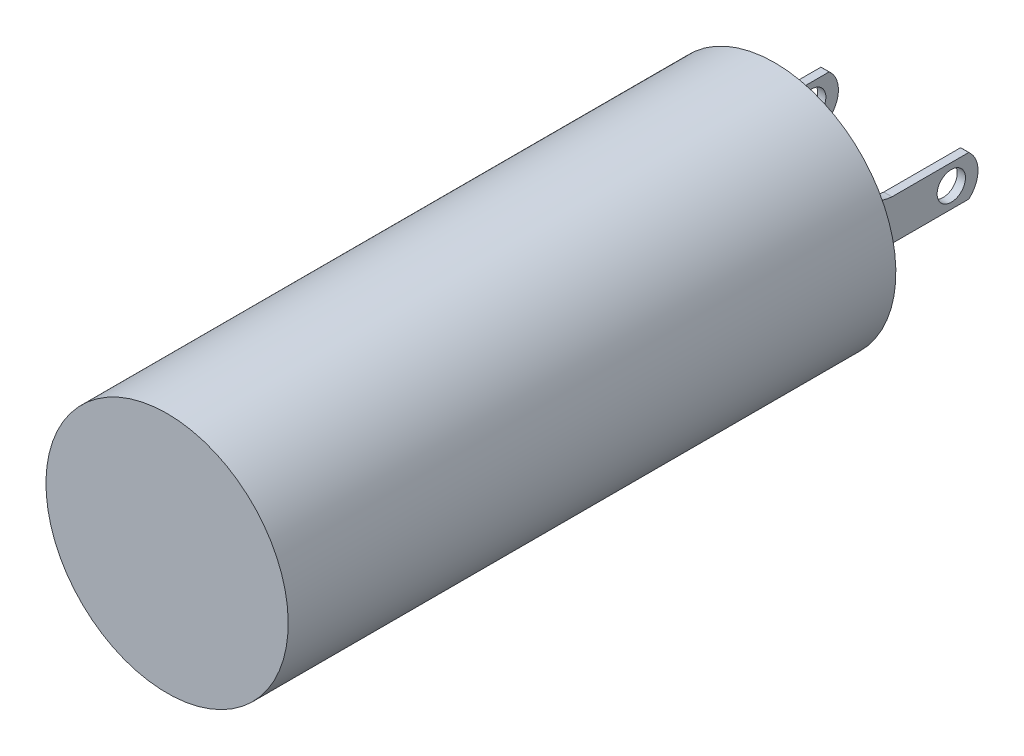
from build123d import *

# Parameters (mm, degrees)
SKETCH3_R           = 0.35052
BOSS_EXTRUDE1_DEPTH = 0.2032


with BuildPart() as part:
    # Sketch1 → Revolve1 (revolve)
    with BuildSketch(Plane(origin=(0, 0, 0), x_dir=(0, 0, -1), z_dir=(1, 0, 0))):
        Polygon((0, 0), (0, 2.9972), (15.0368, 2.9972), (15.0368, 1.5875), (15.4178, 1.5875), (15.4178, 0), align=None)
    revolve(axis=Axis((0, 0, -15.4178), (0, 0, 1)))

    # Sketch3 → Boss-Extrude1 (add)
    with BuildSketch(Plane(origin=(1.6256, 0, 0), x_dir=(0, 0, -1), z_dir=(1, 0, 0))):
        with BuildLine():
            Line((15.0368, 0.635), (15.0368, -0.635))
            Line((15.0368, -0.635), (15.6718, -0.635))
            ThreePointArc((15.6718, -0.635), (15.882828569, -0.543684888), (16.108651936, -0.50038))
            Line((16.108651936, -0.50038), (18.0086, -0.50038))
            ThreePointArc((18.0086, -0.50038), (18.237732209, 0), (18.0086, 0.50038))
            Line((18.0086, 0.50038), (16.108651936, 0.50038))
            ThreePointArc((16.108651936, 0.50038), (15.882828569, 0.543684888), (15.6718, 0.635))
            Line((15.6718, 0.635), (15.0368, 0.635))
        make_face()
        with Locations((17.5768, 0)):
            Circle(SKETCH3_R, mode=Mode.SUBTRACT)
    boss_extrude1 = extrude(amount=BOSS_EXTRUDE1_DEPTH)

    # Mirror1: Boss-Extrude1 across plane
    add(boss_extrude1.mirror(Plane(origin=(0, 0, 0), x_dir=(0, 0, 1), z_dir=(1, 0, 0))))


solid = part.part
